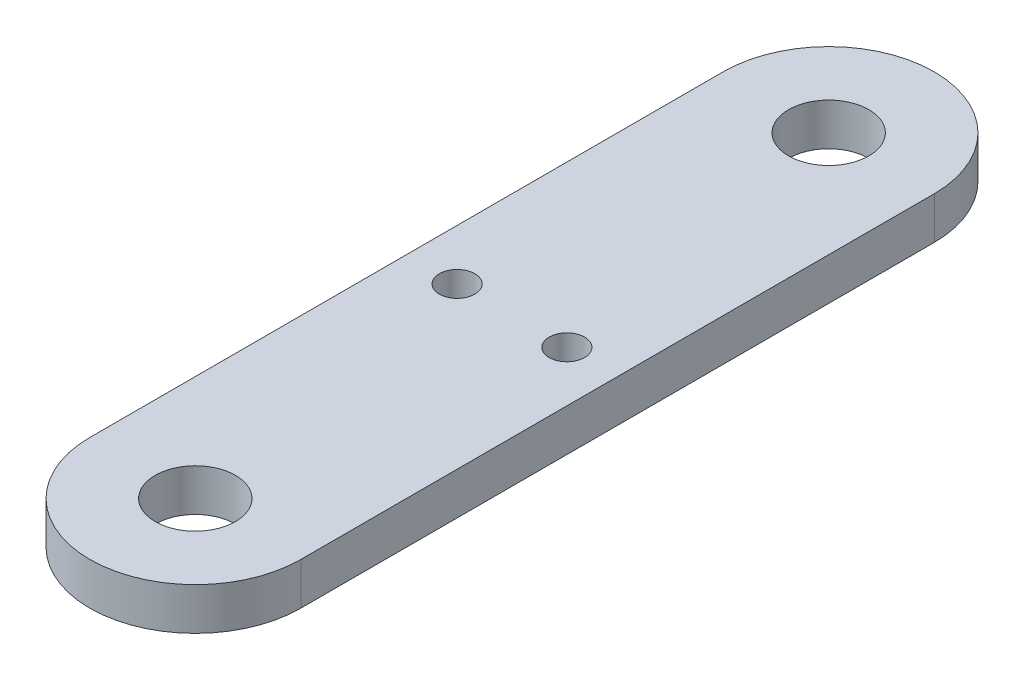
from build123d import *

# Parameters (mm, degrees)
SKETCH1_R           = 12.5
SKETCH1_R_2         = 4.75
SKETCH1_R_3         = 2.1
BOSS_EXTRUDE1_DEPTH = 5


with BuildPart() as part:
    # Sketch1 → Boss-Extrude1 (new body)
    with BuildSketch(Plane(origin=(0, 0, 0), x_dir=(1, 0, 0), z_dir=(0, 1, 0))):
        with Locations((0, 37.5)):
            Circle(SKETCH1_R)
        with Locations((0, 37.5)):
            Circle(SKETCH1_R_2, mode=Mode.SUBTRACT)
        with BuildLine():
            ThreePointArc((-12.5, -37.5), (0, -25), (12.5, -37.5))
            Line((12.5, -37.5), (12.5, 37.5))
            ThreePointArc((12.5, 37.5), (4.5e-08, 25), (-12.5, 37.49999991))
            Line((-12.5, 37.49999991), (-12.5, -37.5))
        make_face()
        with Locations((-6.5, 0)):
            Circle(SKETCH1_R_3, mode=Mode.SUBTRACT)
        with Locations((6.5, 0)):
            Circle(SKETCH1_R_3, mode=Mode.SUBTRACT)
        with Locations((0, -37.5)):
            Circle(SKETCH1_R)
        with Locations((0, -37.5)):
            Circle(SKETCH1_R_2, mode=Mode.SUBTRACT)
    extrude(amount=BOSS_EXTRUDE1_DEPTH)


solid = part.part
